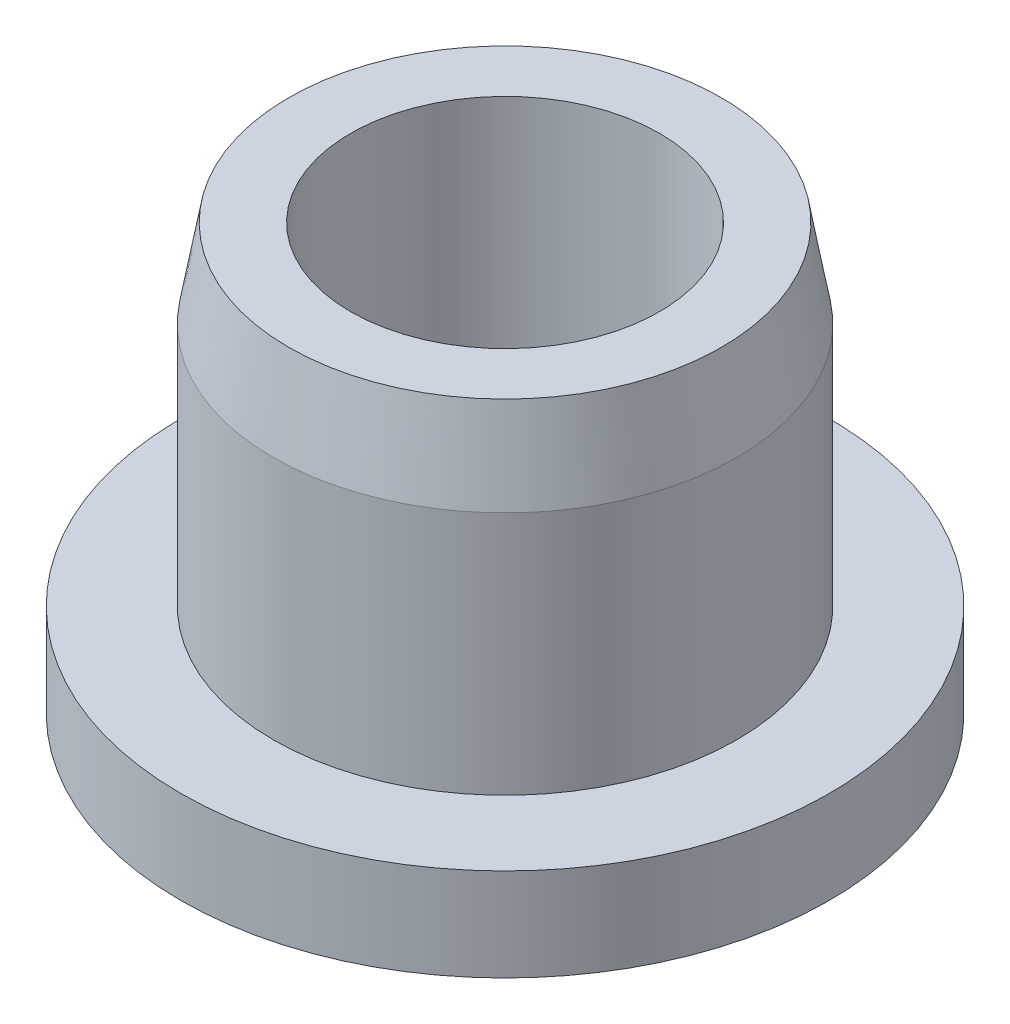
from build123d import *

# Parameters (mm, degrees)
SKETCH2_R           = 4.2
BOSS_EXTRUDE1_DEPTH = 1.2
SKETCH3_R           = 3
BOSS_EXTRUDE2_DEPTH = 4.3
SKETCH4_OUTSIDE_W   = 14.534
SKETCH4_OUTSIDE_H   = 14.534
SKETCH4_OUTSIDE_R   = 2.8
CUT_EXTRUDE1_DEPTH  = 4.3
CUT_EXTRUDE1_TAPER  = 10
SKETCH5_R           = 2
CUT_EXTRUDE2_DEPTH  = 6.5


with BuildPart() as part:
    # Sketch2 → Boss-Extrude1 (new body)
    with BuildSketch(Plane(origin=(0, 0, 0), x_dir=(1, 0, 0), z_dir=(0, 1, 0))):
        Circle(SKETCH2_R)
    extrude(amount=BOSS_EXTRUDE1_DEPTH)

    # Sketch3 → Boss-Extrude2 (add)
    with BuildSketch(Plane(origin=(0, 1.2, 0), x_dir=(1, 0, 0), z_dir=(0, 1, 0))):
        Circle(SKETCH3_R)
    extrude(amount=BOSS_EXTRUDE2_DEPTH)

    # Sketch4 outside → Cut-Extrude1 (cut)
    with BuildSketch(Plane(origin=(0, 5.5, 0), x_dir=(1, 0, 0), z_dir=(0, 1, 0))):
        Rectangle(SKETCH4_OUTSIDE_W, SKETCH4_OUTSIDE_H)
        Circle(SKETCH4_OUTSIDE_R, mode=Mode.SUBTRACT)
    extrude(amount=-CUT_EXTRUDE1_DEPTH, taper=CUT_EXTRUDE1_TAPER, mode=Mode.SUBTRACT)

    # Sketch5 → Cut-Extrude2 (cut, through all)
    with BuildSketch(Plane(origin=(0, 5.5, 0), x_dir=(1, 0, 0), z_dir=(0, 1, 0))):
        Circle(SKETCH5_R)
    extrude(amount=-CUT_EXTRUDE2_DEPTH, mode=Mode.SUBTRACT)


solid = part.part
